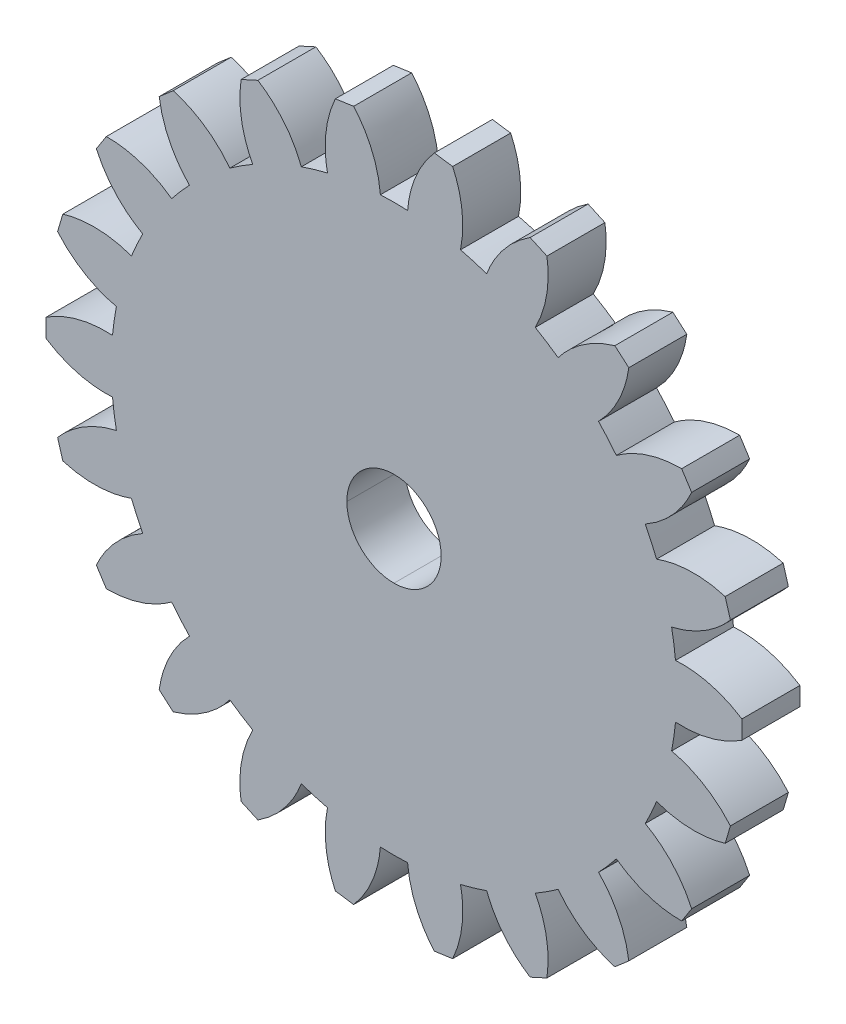
from build123d import *

# Parameters (mm, degrees)
SALIENTE_EXTRUIR1_DEPTH = 4


with BuildPart() as part:
    # Croquis1 → Saliente-Extruir1 (new body)
    with BuildSketch(Plane.XY):
        with BuildLine():
            add(Edge.make_bspline(
                [(396.246821741, -350.001451857), (396.628245074, -350.188036024), (397.014536741, -350.364424912), (397.405308685, -350.53051269)],
                knots=[0, 0, 0, 0, 1, 1, 1, 1], degree=3))
            add(Edge.make_bspline(
                [(397.405308685, -350.53051269), (398.773451463, -349.663949357), (399.825258407, -348.378850468), (400.404272574, -346.866386302)],
                knots=[0, 0, 0, 0, 1, 1, 1, 1], degree=3))
            add(Edge.make_bspline(
                [(400.404272574, -346.866386302), (400.99598674, -347.071561858), (401.597225907, -347.248127135), (402.205943962, -347.395411858)],
                knots=[0, 0, 0, 0, 1, 1, 1, 1], degree=3))
            add(Edge.make_bspline(
                [(402.205943962, -347.395411858), (401.875355906, -348.980795191), (402.065432573, -350.630560468), (402.747881184, -352.099244912)],
                knots=[0, 0, 0, 0, 1, 1, 1, 1], degree=3))
            add(Edge.make_bspline(
                [(402.747881184, -352.099244912), (403.166381462, -352.170788245), (403.586751462, -352.231219079), (404.008462017, -352.280466856)],
                knots=[0, 0, 0, 0, 1, 1, 1, 1], degree=3))
            add(Edge.make_bspline(
                [(404.008462017, -352.280466856), (405.077025906, -351.063559912), (405.724196739, -349.53419769), (405.853630905, -347.91988658)],
                knots=[0, 0, 0, 0, 1, 1, 1, 1], degree=3))
            add(Edge.make_bspline(
                [(405.853630905, -347.91988658), (406.479211739, -347.95004908), (407.105850905, -347.95004908), (407.731396461, -347.91988658)],
                knots=[0, 0, 0, 0, 1, 1, 1, 1], degree=3))
            add(Edge.make_bspline(
                [(407.731396461, -347.91988658), (407.860830627, -349.53419769), (408.50800146, -351.063559912), (409.576565349, -352.280466856)],
                knots=[0, 0, 0, 0, 1, 1, 1, 1], degree=3))
            add(Edge.make_bspline(
                [(409.576565349, -352.280466856), (409.998311182, -352.231219079), (410.418645904, -352.170788245), (410.83718146, -352.099244912)],
                knots=[0, 0, 0, 0, 1, 1, 1, 1], degree=3))
            add(Edge.make_bspline(
                [(410.83718146, -352.099244912), (411.519630071, -350.630560468), (411.70967146, -348.980795191), (411.379083404, -347.395411858)],
                knots=[0, 0, 0, 0, 1, 1, 1, 1], degree=3))
            add(Edge.make_bspline(
                [(411.379083404, -347.395411858), (411.98780146, -347.248127135), (412.589075904, -347.071561858), (413.18079007, -346.866386302)],
                knots=[0, 0, 0, 0, 1, 1, 1, 1], degree=3))
            add(Edge.make_bspline(
                [(413.18079007, -346.866386302), (413.759768959, -348.378850468), (414.811611181, -349.663949357), (416.179753958, -350.53051269)],
                knots=[0, 0, 0, 0, 1, 1, 1, 1], degree=3))
            add(Edge.make_bspline(
                [(416.179753958, -350.53051269), (416.570490625, -350.364424912), (416.956782292, -350.188036024), (417.338205625, -350.001451857)],
                knots=[0, 0, 0, 0, 1, 1, 1, 1], degree=3))
            add(Edge.make_bspline(
                [(417.338205625, -350.001451857), (417.579223403, -348.400017135), (417.296824792, -346.76355158), (416.532955069, -345.335507136)],
                knots=[0, 0, 0, 0, 1, 1, 1, 1], degree=3))
            add(Edge.make_bspline(
                [(416.532955069, -345.335507136), (417.075492014, -345.02269908), (417.602683125, -344.683891303), (418.112623402, -344.320318525)],
                knots=[0, 0, 0, 0, 1, 1, 1, 1], degree=3))
            add(Edge.make_bspline(
                [(418.112623402, -344.320318525), (419.094262847, -345.608380747), (420.465545346, -346.54511158), (422.022388957, -346.991093247)],
                knots=[0, 0, 0, 0, 1, 1, 1, 1], degree=3))
            add(Edge.make_bspline(
                [(422.022388957, -346.991093247), (422.350542846, -346.721676858), (422.671500068, -346.443582136), (422.984872568, -346.157091302)],
                knots=[0, 0, 0, 0, 1, 1, 1, 1], degree=3))
            add(Edge.make_bspline(
                [(422.984872568, -346.157091302), (422.764986179, -344.552622692), (422.032937013, -343.06199547), (420.897698124, -341.907036303)],
                knots=[0, 0, 0, 0, 1, 1, 1, 1], degree=3))
            add(Edge.make_bspline(
                [(420.897698124, -341.907036303), (421.330168402, -341.454034359), (421.740519513, -340.980430193), (422.127375624, -340.487917137)],
                knots=[0, 0, 0, 0, 1, 1, 1, 1], degree=3))
            add(Edge.make_bspline(
                [(422.127375624, -340.487917137), (423.432159512, -341.447225748), (425.011792567, -341.959670748), (426.631218956, -341.949016859)],
                knots=[0, 0, 0, 0, 1, 1, 1, 1], degree=3))
            add(Edge.make_bspline(
                [(426.631218956, -341.949016859), (426.870190622, -341.598038248), (427.0997784, -341.240780192), (427.319770622, -340.877630748)],
                knots=[0, 0, 0, 0, 1, 1, 1, 1], degree=3))
            add(Edge.make_bspline(
                [(427.319770622, -340.877630748), (426.656724789, -339.400091582), (425.534397567, -338.176093804), (424.119758679, -337.387741305)],
                knots=[0, 0, 0, 0, 1, 1, 1, 1], degree=3))
            add(Edge.make_bspline(
                [(424.119758679, -337.387741305), (424.407025623, -336.83123436), (424.667375623, -336.261216027), (424.899785623, -335.679661861)],
                knots=[0, 0, 0, 0, 1, 1, 1, 1], degree=3))
            add(Edge.make_bspline(
                [(424.899785623, -335.679661861), (426.421986456, -336.232535194), (428.082017567, -336.279172416), (429.632828677, -335.81269436)],
                knots=[0, 0, 0, 0, 1, 1, 1, 1], degree=3))
            add(Edge.make_bspline(
                [(429.632828677, -335.81269436), (429.763250622, -335.408622694), (429.882877566, -335.001129083), (429.991638955, -334.590707416)],
                knots=[0, 0, 0, 0, 1, 1, 1, 1], degree=3))
            add(Edge.make_bspline(
                [(429.991638955, -334.590707416), (428.939197011, -333.359830472), (427.517502567, -332.501627972), (425.9380459, -332.143734917)],
                knots=[0, 0, 0, 0, 1, 1, 1, 1], degree=3))
            add(Edge.make_bspline(
                [(425.9380459, -332.143734917), (426.056896734, -331.52884325), (426.146078956, -330.908589362), (426.205275067, -330.285089917)],
                knots=[0, 0, 0, 0, 1, 1, 1, 1], degree=3))
            add(Edge.make_bspline(
                [(426.205275067, -330.285089917), (427.821561733, -330.386725195), (429.427476733, -329.963815195), (430.784083677, -329.079295473)],
                knots=[0, 0, 0, 0, 1, 1, 1, 1], degree=3))
            add(Edge.make_bspline(
                [(430.784083677, -329.079295473), (430.795337288, -328.654833251), (430.795337288, -328.230159362), (430.784083677, -327.805732418)],
                knots=[0, 0, 0, 0, 1, 1, 1, 1], degree=3))
            add(Edge.make_bspline(
                [(430.784083677, -327.805732418), (429.427476733, -326.921212696), (427.821561733, -326.498302696), (426.205275067, -326.599902696)],
                knots=[0, 0, 0, 0, 1, 1, 1, 1], degree=3))
            add(Edge.make_bspline(
                [(426.205275067, -326.599902696), (426.146078956, -325.97643853), (426.056896734, -325.356149363), (425.9380459, -324.741257697)],
                knots=[0, 0, 0, 0, 1, 1, 1, 1], degree=3))
            add(Edge.make_bspline(
                [(425.9380459, -324.741257697), (427.517502567, -324.383399919), (428.939197011, -323.525162141), (429.991638955, -322.294285197)],
                knots=[0, 0, 0, 0, 1, 1, 1, 1], degree=3))
            add(Edge.make_bspline(
                [(429.991638955, -322.294285197), (429.882877566, -321.883863531), (429.763250622, -321.476405197), (429.632828677, -321.072333531)],
                knots=[0, 0, 0, 0, 1, 1, 1, 1], degree=3))
            add(Edge.make_bspline(
                [(429.632828677, -321.072333531), (428.082017567, -320.605820198), (426.421986456, -320.652492698), (424.899785623, -321.205330753)],
                knots=[0, 0, 0, 0, 1, 1, 1, 1], degree=3))
            add(Edge.make_bspline(
                [(424.899785623, -321.205330753), (424.667375623, -320.623776587), (424.407025623, -320.053758253), (424.119758679, -319.497286587)],
                knots=[0, 0, 0, 0, 1, 1, 1, 1], degree=3))
            add(Edge.make_bspline(
                [(424.119758679, -319.497286587), (425.534397567, -318.708934087), (426.656724789, -317.484901032), (427.319770622, -316.007397143)],
                knots=[0, 0, 0, 0, 1, 1, 1, 1], degree=3))
            add(Edge.make_bspline(
                [(427.319770622, -316.007397143), (427.0997784, -315.644212421), (426.870190622, -315.286989643), (426.631218956, -314.936011032)],
                knots=[0, 0, 0, 0, 1, 1, 1, 1], degree=3))
            add(Edge.make_bspline(
                [(426.631218956, -314.936011032), (425.011792567, -314.925321866), (423.432159512, -315.437766866), (422.127375624, -316.397075476)],
                knots=[0, 0, 0, 0, 1, 1, 1, 1], degree=3))
            add(Edge.make_bspline(
                [(422.127375624, -316.397075476), (421.740519513, -315.904562421), (421.330168402, -315.430993532), (420.897698124, -314.97795631)],
                knots=[0, 0, 0, 0, 1, 1, 1, 1], degree=3))
            add(Edge.make_bspline(
                [(420.897698124, -314.97795631), (422.032937013, -313.822997144), (422.764986179, -312.332369922), (422.984872568, -310.727901311)],
                knots=[0, 0, 0, 0, 1, 1, 1, 1], degree=3))
            add(Edge.make_bspline(
                [(422.984872568, -310.727901311), (422.671500068, -310.441445756), (422.350542846, -310.163351034), (422.022388957, -309.893899367)],
                knots=[0, 0, 0, 0, 1, 1, 1, 1], degree=3))
            add(Edge.make_bspline(
                [(422.022388957, -309.893899367), (420.465545346, -310.339916311), (419.094262847, -311.276611867), (418.112623402, -312.564674089)],
                knots=[0, 0, 0, 0, 1, 1, 1, 1], degree=3))
            add(Edge.make_bspline(
                [(418.112623402, -312.564674089), (417.602683125, -312.201101311), (417.075492014, -311.862328811), (416.532955069, -311.549485478)],
                knots=[0, 0, 0, 0, 1, 1, 1, 1], degree=3))
            add(Edge.make_bspline(
                [(416.532955069, -311.549485478), (417.296824792, -310.121476311), (417.579223403, -308.485010756), (417.338205625, -306.883540757)],
                knots=[0, 0, 0, 0, 1, 1, 1, 1], degree=3))
            add(Edge.make_bspline(
                [(417.338205625, -306.883540757), (416.956782292, -306.696991868), (416.570490625, -306.520567701), (416.179753958, -306.354479923)],
                knots=[0, 0, 0, 0, 1, 1, 1, 1], degree=3))
            add(Edge.make_bspline(
                [(416.179753958, -306.354479923), (414.811611181, -307.221043257), (413.759768959, -308.506142145), (413.18079007, -310.018606311)],
                knots=[0, 0, 0, 0, 1, 1, 1, 1], degree=3))
            add(Edge.make_bspline(
                [(413.18079007, -310.018606311), (412.589075904, -309.813430756), (411.98780146, -309.636900756), (411.379083404, -309.489580756)],
                knots=[0, 0, 0, 0, 1, 1, 1, 1], degree=3))
            add(Edge.make_bspline(
                [(411.379083404, -309.489580756), (411.70967146, -307.904197423), (411.519630071, -306.254432146), (410.83718146, -304.785782979)],
                knots=[0, 0, 0, 0, 1, 1, 1, 1], degree=3))
            add(Edge.make_bspline(
                [(410.83718146, -304.785782979), (410.418645904, -304.714204368), (409.998311182, -304.653773535), (409.576565349, -304.604525757)],
                knots=[0, 0, 0, 0, 1, 1, 1, 1], degree=3))
            add(Edge.make_bspline(
                [(409.576565349, -304.604525757), (408.50800146, -305.821432701), (407.860830627, -307.350830201), (407.731396461, -308.965106034)],
                knots=[0, 0, 0, 0, 1, 1, 1, 1], degree=3))
            add(Edge.make_bspline(
                [(407.731396461, -308.965106034), (407.105850905, -308.934978812), (406.479211739, -308.934978812), (405.853630905, -308.965106034)],
                knots=[0, 0, 0, 0, 1, 1, 1, 1], degree=3))
            add(Edge.make_bspline(
                [(405.853630905, -308.965106034), (405.724196739, -307.350830201), (405.077025906, -305.821432701), (404.008462017, -304.604525757)],
                knots=[0, 0, 0, 0, 1, 1, 1, 1], degree=3))
            add(Edge.make_bspline(
                [(404.008462017, -304.604525757), (403.586751462, -304.653773535), (403.166381462, -304.714204368), (402.747881184, -304.785782979)],
                knots=[0, 0, 0, 0, 1, 1, 1, 1], degree=3))
            add(Edge.make_bspline(
                [(402.747881184, -304.785782979), (402.065432573, -306.254432146), (401.875355906, -307.904197423), (402.205943962, -309.489580756)],
                knots=[0, 0, 0, 0, 1, 1, 1, 1], degree=3))
            add(Edge.make_bspline(
                [(402.205943962, -309.489580756), (401.597225907, -309.636900756), (400.99598674, -309.813430756), (400.404272574, -310.018606311)],
                knots=[0, 0, 0, 0, 1, 1, 1, 1], degree=3))
            add(Edge.make_bspline(
                [(400.404272574, -310.018606311), (399.825258407, -308.506142145), (398.773451463, -307.221043257), (397.405308685, -306.354479923)],
                knots=[0, 0, 0, 0, 1, 1, 1, 1], degree=3))
            add(Edge.make_bspline(
                [(397.405308685, -306.354479923), (397.014536741, -306.520567701), (396.628245074, -306.696991868), (396.246821741, -306.883540757)],
                knots=[0, 0, 0, 0, 1, 1, 1, 1], degree=3))
            add(Edge.make_bspline(
                [(396.246821741, -306.883540757), (396.005803963, -308.485010756), (396.288237852, -310.121476311), (397.052072297, -311.549485478)],
                knots=[0, 0, 0, 0, 1, 1, 1, 1], degree=3))
            add(Edge.make_bspline(
                [(397.052072297, -311.549485478), (396.509535352, -311.862328811), (395.982379519, -312.201101311), (395.472403964, -312.564674089)],
                knots=[0, 0, 0, 0, 1, 1, 1, 1], degree=3))
            add(Edge.make_bspline(
                [(395.472403964, -312.564674089), (394.490764519, -311.276611867), (393.11948202, -310.339916311), (391.562638409, -309.893899367)],
                knots=[0, 0, 0, 0, 1, 1, 1, 1], degree=3))
            add(Edge.make_bspline(
                [(391.562638409, -309.893899367), (391.23448452, -310.163351034), (390.913562576, -310.441445756), (390.600154798, -310.727901311)],
                knots=[0, 0, 0, 0, 1, 1, 1, 1], degree=3))
            add(Edge.make_bspline(
                [(390.600154798, -310.727901311), (390.820076465, -312.332369922), (391.552090354, -313.822997144), (392.687329242, -314.97795631)],
                knots=[0, 0, 0, 0, 1, 1, 1, 1], degree=3))
            add(Edge.make_bspline(
                [(392.687329242, -314.97795631), (392.254894242, -315.430993532), (391.844507853, -315.904562421), (391.457651742, -316.397075476)],
                knots=[0, 0, 0, 0, 1, 1, 1, 1], degree=3))
            add(Edge.make_bspline(
                [(391.457651742, -316.397075476), (390.152867854, -315.437766866), (388.573270076, -314.925321866), (386.95380841, -314.936011032)],
                knots=[0, 0, 0, 0, 1, 1, 1, 1], degree=3))
            add(Edge.make_bspline(
                [(386.95380841, -314.936011032), (386.714872021, -315.286989643), (386.485284244, -315.644212421), (386.265292021, -316.007397143)],
                knots=[0, 0, 0, 0, 1, 1, 1, 1], degree=3))
            add(Edge.make_bspline(
                [(386.265292021, -316.007397143), (386.928302577, -317.484901032), (388.050629799, -318.708934087), (389.465303965, -319.497286587)],
                knots=[0, 0, 0, 0, 1, 1, 1, 1], degree=3))
            add(Edge.make_bspline(
                [(389.465303965, -319.497286587), (389.178001743, -320.053758253), (388.917687021, -320.623776587), (388.685241743, -321.205330753)],
                knots=[0, 0, 0, 0, 1, 1, 1, 1], degree=3))
            add(Edge.make_bspline(
                [(388.685241743, -321.205330753), (387.16304091, -320.652492698), (385.503045077, -320.605820198), (383.952198689, -321.072333531)],
                knots=[0, 0, 0, 0, 1, 1, 1, 1], degree=3))
            add(Edge.make_bspline(
                [(383.952198689, -321.072333531), (383.821812022, -321.476405197), (383.7021498, -321.883863531), (383.593388411, -322.294285197)],
                knots=[0, 0, 0, 0, 1, 1, 1, 1], degree=3))
            add(Edge.make_bspline(
                [(383.593388411, -322.294285197), (384.645830355, -323.525162141), (386.067560077, -324.383399919), (387.647016743, -324.741257697)],
                knots=[0, 0, 0, 0, 1, 1, 1, 1], degree=3))
            add(Edge.make_bspline(
                [(387.647016743, -324.741257697), (387.528130632, -325.356149363), (387.43894841, -325.97643853), (387.379787577, -326.599902696)],
                knots=[0, 0, 0, 0, 1, 1, 1, 1], degree=3))
            add(Edge.make_bspline(
                [(387.379787577, -326.599902696), (385.763465633, -326.498302696), (384.157550633, -326.921212696), (382.800978967, -327.805732418)],
                knots=[0, 0, 0, 0, 1, 1, 1, 1], degree=3))
            add(Edge.make_bspline(
                [(382.800978967, -327.805732418), (382.789690078, -328.230159362), (382.789690078, -328.654833251), (382.800978967, -329.079295473)],
                knots=[0, 0, 0, 0, 1, 1, 1, 1], degree=3))
            add(Edge.make_bspline(
                [(382.800978967, -329.079295473), (384.157550633, -329.963815195), (385.763465633, -330.386725195), (387.379787577, -330.285089917)],
                knots=[0, 0, 0, 0, 1, 1, 1, 1], degree=3))
            add(Edge.make_bspline(
                [(387.379787577, -330.285089917), (387.43894841, -330.908589362), (387.528130632, -331.52884325), (387.647016743, -332.143734917)],
                knots=[0, 0, 0, 0, 1, 1, 1, 1], degree=3))
            add(Edge.make_bspline(
                [(387.647016743, -332.143734917), (386.067560077, -332.501627972), (384.645830355, -333.359830472), (383.593388411, -334.590707416)],
                knots=[0, 0, 0, 0, 1, 1, 1, 1], degree=3))
            add(Edge.make_bspline(
                [(383.593388411, -334.590707416), (383.7021498, -335.001129083), (383.821812022, -335.408622694), (383.952198689, -335.81269436)],
                knots=[0, 0, 0, 0, 1, 1, 1, 1], degree=3))
            add(Edge.make_bspline(
                [(383.952198689, -335.81269436), (385.503045077, -336.279172416), (387.16304091, -336.232535194), (388.685241743, -335.679661861)],
                knots=[0, 0, 0, 0, 1, 1, 1, 1], degree=3))
            add(Edge.make_bspline(
                [(388.685241743, -335.679661861), (388.917687021, -336.261216027), (389.178001743, -336.83123436), (389.465303965, -337.387741305)],
                knots=[0, 0, 0, 0, 1, 1, 1, 1], degree=3))
            add(Edge.make_bspline(
                [(389.465303965, -337.387741305), (388.050629799, -338.176093804), (386.928302577, -339.400091582), (386.265292021, -340.877630748)],
                knots=[0, 0, 0, 0, 1, 1, 1, 1], degree=3))
            add(Edge.make_bspline(
                [(386.265292021, -340.877630748), (386.485284244, -341.240780192), (386.714872021, -341.598038248), (386.95380841, -341.949016859)],
                knots=[0, 0, 0, 0, 1, 1, 1, 1], degree=3))
            add(Edge.make_bspline(
                [(386.95380841, -341.949016859), (388.573270076, -341.959670748), (390.152867854, -341.447225748), (391.457651742, -340.487917137)],
                knots=[0, 0, 0, 0, 1, 1, 1, 1], degree=3))
            add(Edge.make_bspline(
                [(391.457651742, -340.487917137), (391.844507853, -340.980430193), (392.254894242, -341.454034359), (392.687329242, -341.907036303)],
                knots=[0, 0, 0, 0, 1, 1, 1, 1], degree=3))
            add(Edge.make_bspline(
                [(392.687329242, -341.907036303), (391.552090354, -343.06199547), (390.820076465, -344.552622692), (390.600154798, -346.157091302)],
                knots=[0, 0, 0, 0, 1, 1, 1, 1], degree=3))
            add(Edge.make_bspline(
                [(390.600154798, -346.157091302), (390.913562576, -346.443582136), (391.23448452, -346.721676858), (391.562638409, -346.991093247)],
                knots=[0, 0, 0, 0, 1, 1, 1, 1], degree=3))
            add(Edge.make_bspline(
                [(391.562638409, -346.991093247), (393.11948202, -346.54511158), (394.490764519, -345.608380747), (395.472403964, -344.320318525)],
                knots=[0, 0, 0, 0, 1, 1, 1, 1], degree=3))
            add(Edge.make_bspline(
                [(395.472403964, -344.320318525), (395.982379519, -344.683891303), (396.509535352, -345.02269908), (397.052072297, -345.335507136)],
                knots=[0, 0, 0, 0, 1, 1, 1, 1], degree=3))
            add(Edge.make_bspline(
                [(397.052072297, -345.335507136), (396.288237852, -346.76355158), (396.005803963, -348.400017135), (396.246821741, -350.001451857)],
                knots=[0, 0, 0, 0, 1, 1, 1, 1], degree=3))
        make_face()
        with BuildLine():
            add(Edge.make_bspline(
                [(403.542513128, -328.442496307), (403.542513128, -326.647598252), (404.99758035, -325.19253103), (406.792513683, -325.19253103)],
                knots=[0, 0, 0, 0, 1, 1, 1, 1], degree=3))
            add(Edge.make_bspline(
                [(406.792513683, -325.19253103), (408.587447016, -325.19253103), (410.042514238, -326.647598252), (410.042514238, -328.442496307)],
                knots=[1, 1, 1, 1, 2, 2, 2, 2], degree=3))
            add(Edge.make_bspline(
                [(410.042514238, -328.442496307), (410.042514238, -330.23742964), (408.587447016, -331.692496862), (406.792513683, -331.692496862)],
                knots=[2, 2, 2, 2, 3, 3, 3, 3], degree=3))
            add(Edge.make_bspline(
                [(406.792513683, -331.692496862), (404.99758035, -331.692496862), (403.542513128, -330.23742964), (403.542513128, -328.442496307)],
                knots=[3, 3, 3, 3, 4, 4, 4, 4], degree=3))
        make_face(mode=Mode.SUBTRACT)
    extrude(amount=SALIENTE_EXTRUIR1_DEPTH)


solid = part.part
